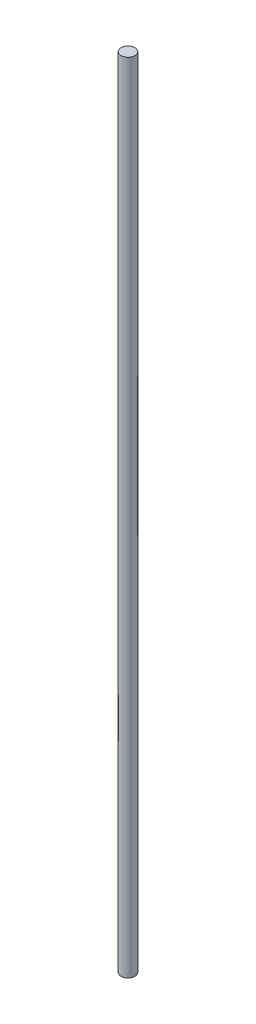
from build123d import *

# Parameters (mm, degrees)
SKETCH1_R           = 7.9375
BOSS_EXTRUDE1_DEPTH = 914.4


with BuildPart() as part:
    # Sketch1 → Boss-Extrude1 (new body)
    with BuildSketch(Plane(origin=(0, 0, 0), x_dir=(1, 0, 0), z_dir=(0, 1, 0))):
        Circle(SKETCH1_R)
    extrude(amount=BOSS_EXTRUDE1_DEPTH)


solid = part.part
